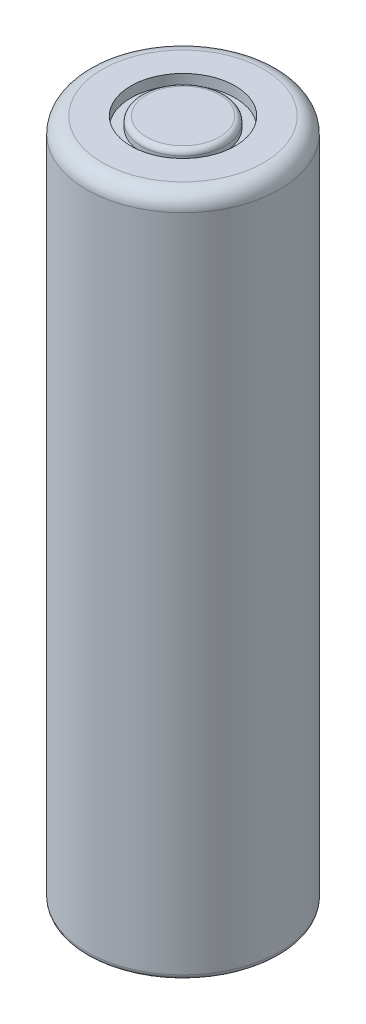
from build123d import *

# Parameters (mm, degrees)
SKIZZE1_R                       = 9.25
AUFSATZ_LINEAR_AUSTRAGEN1_DEPTH = 65.3
VERRUNDUNG1_R                   = 1.5
VERRUNDUNG2_R                   = 0.5
SKIZZE2_R                       = 5
SKIZZE2_R_2                     = 4
SCHNITT_LINEAR_AUSTRAGEN1_DEPTH = 1
VERRUNDUNG3_R                   = 0.5


with BuildPart() as part:
    # Skizze1 → Aufsatz-Linear austragen1 (new body)
    with BuildSketch(Plane(origin=(0, 0, 0), x_dir=(1, 0, 0), z_dir=(0, 1, 0))):
        Circle(SKIZZE1_R)
    extrude(amount=AUFSATZ_LINEAR_AUSTRAGEN1_DEPTH)

    # Verrundung1
    verrundung1_edges = [part.edges().sort_by_distance(p)[0] for p in [
        (-9.25, 65.3, 0),
    ]]
    fillet(verrundung1_edges, radius=VERRUNDUNG1_R)

    # Verrundung2
    verrundung2_edges = [part.edges().sort_by_distance(p)[0] for p in [
        (-9.25, 0, 0),
    ]]
    fillet(verrundung2_edges, radius=VERRUNDUNG2_R)

    # Skizze2 → Schnitt-Linear austragen1 (cut)
    with BuildSketch(Plane(origin=(0, 65.3, 0), x_dir=(1, 0, 0), z_dir=(0, 1, 0))):
        Circle(SKIZZE2_R)
        Circle(SKIZZE2_R_2, mode=Mode.SUBTRACT)
    extrude(amount=-SCHNITT_LINEAR_AUSTRAGEN1_DEPTH, mode=Mode.SUBTRACT)

    # Verrundung3
    verrundung3_edges = [part.edges().sort_by_distance(p)[0] for p in [
        (-4, 65.3, 0),
    ]]
    fillet(verrundung3_edges, radius=VERRUNDUNG3_R)


solid = part.part
